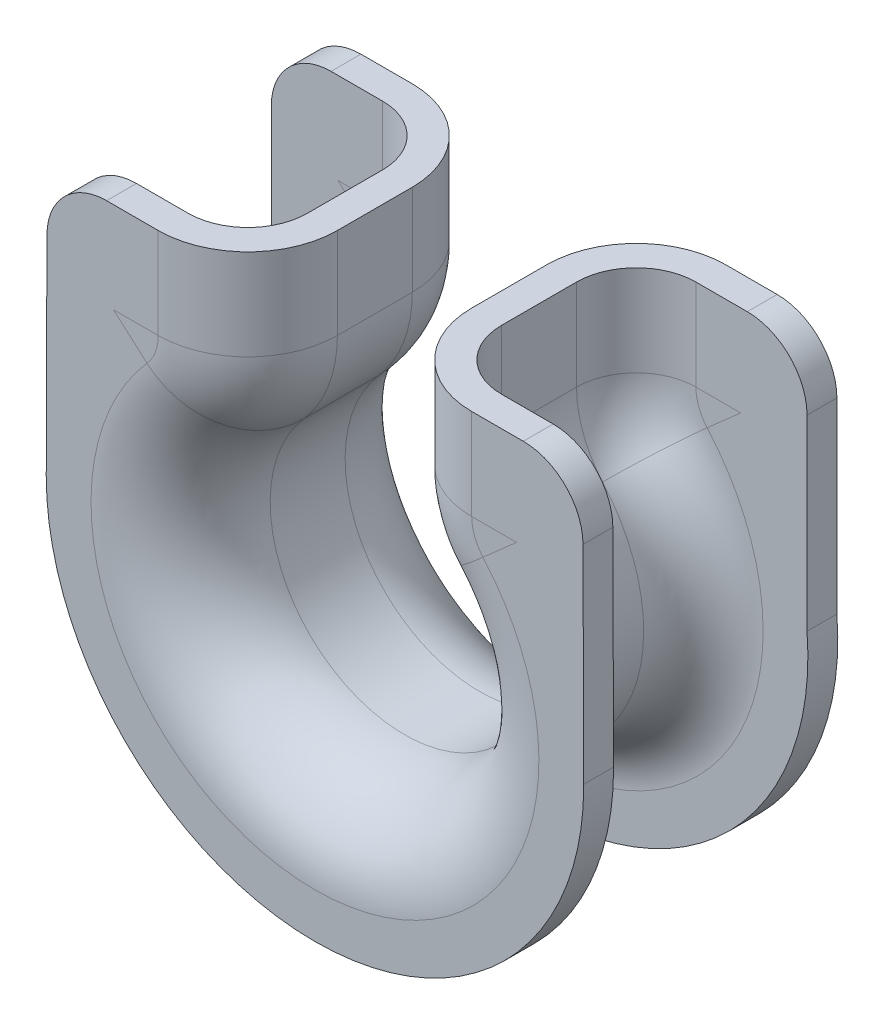
from build123d import *

# Parameters (mm, degrees)
BOSS_EXTRUDE1_START = -8.508956
BOSS_EXTRUDE1_DEPTH = 2
BOSS_EXTRUDE2_START = 8.508956
BOSS_EXTRUDE2_DEPTH = 2
FILLET1_R           = 4


with BuildPart() as part:
    # Sweep2: sweep along a path in Sketch2
    with BuildLine(Plane.XY) as sweep2_path:
        Line((-4.5, 18), (-4.5, 11.9058809))
        ThreePointArc((-4.5, 11.9058809), (-5.08127088, 8.723900384), (-6.75, 5.95294045))
        ThreePointArc((-6.75, 5.95294045), (0, -9), (6.75, 5.95294045))
        ThreePointArc((6.75, 5.95294045), (5.08127088, 8.723900384), (4.5, 11.9058809))
        Line((4.5, 11.9058809), (4.5, 18))
    # Sketch5 → Sweep2 (sweep)
    with BuildSketch(Plane(origin=(0, 0, 0), x_dir=(0, 0, -1), z_dir=(1, 0, 0))):
        with BuildLine():
            Line((-2.508956399, -9), (2.508956399, -9))
            ThreePointArc((2.508956399, -9), (6.751597087, -10.757359313), (8.508956399, -15))
            Line((8.508956399, -15), (8.508956399, -18))
            Line((8.508956399, -18), (6.508956399, -18))
            Line((6.508956399, -18), (6.508956399, -15))
            ThreePointArc((6.508956399, -15), (5.337383524, -12.171572875), (2.508956399, -11))
            Line((2.508956399, -11), (-2.508956399, -11))
            ThreePointArc((-2.508956399, -11), (-5.337383524, -12.171572875), (-6.508956399, -15))
            Line((-6.508956399, -15), (-6.508956399, -18))
            Line((-6.508956399, -18), (-8.508956399, -18))
            Line((-8.508956399, -18), (-8.508956399, -15))
            ThreePointArc((-8.508956399, -15), (-6.751597087, -10.757359313), (-2.508956399, -9))
        make_face()
    sweep(path=sweep2_path.line)

    # Sketch7 → Boss-Extrude1 (add)
    with BuildSketch(Plane.XY.offset(BOSS_EXTRUDE1_START)):
        with BuildLine():
            Line((17.940697807, -1.45991856), (17.940697807, 18))
            Line((17.940697807, 18), (13.5, 18))
            Line((13.5, 18), (13.5, 11.9058809))
            ThreePointArc((13.5, 11.9058809), (16.801469128, 5.58217616), (17.940697807, -1.45991856))
        make_face()
        with BuildLine():
            Line((-13.5, 18), (-13.5, 11.9058809))
            ThreePointArc((-13.5, 11.9058809), (-16.801469128, 5.58217616), (-17.940697807, -1.45991856))
            Line((-17.940697807, -1.45991856), (-17.940697807, 18))
            Line((-17.940697807, 18), (-13.5, 18))
        make_face()
    extrude(amount=BOSS_EXTRUDE1_DEPTH)

    # Sketch9 → Boss-Extrude2 (add)
    with BuildSketch(Plane.XY.offset(BOSS_EXTRUDE2_START)):
        with BuildLine():
            Line((18, 0), (17.940697807, 18))
            Line((17.940697807, 18), (13.5, 18))
            Line((13.5, 18), (13.5, 11.9058809))
            ThreePointArc((13.5, 11.9058809), (16.827327901, 6.360132122), (18, 0))
        make_face()
        with BuildLine():
            Line((-13.5, 18), (-13.5, 11.9058809))
            ThreePointArc((-13.5, 11.9058809), (-16.827327901, 6.360132122), (-18, 0))
            Line((-18, 0), (-17.940697807, 18))
            Line((-17.940697807, 18), (-13.5, 18))
        make_face()
    extrude(amount=-BOSS_EXTRUDE2_DEPTH)

    # Fillet1
    fillet1_edges = [part.edges().sort_by_distance(p)[0] for p in [
        (17.940697807, 18, 7.508956),
        (17.940697807, 18, -7.508956),
        (-17.940697807, 18, 7.508956),
        (-17.940697807, 18, -7.508956),
    ]]
    fillet(fillet1_edges, radius=FILLET1_R)


solid = part.part
